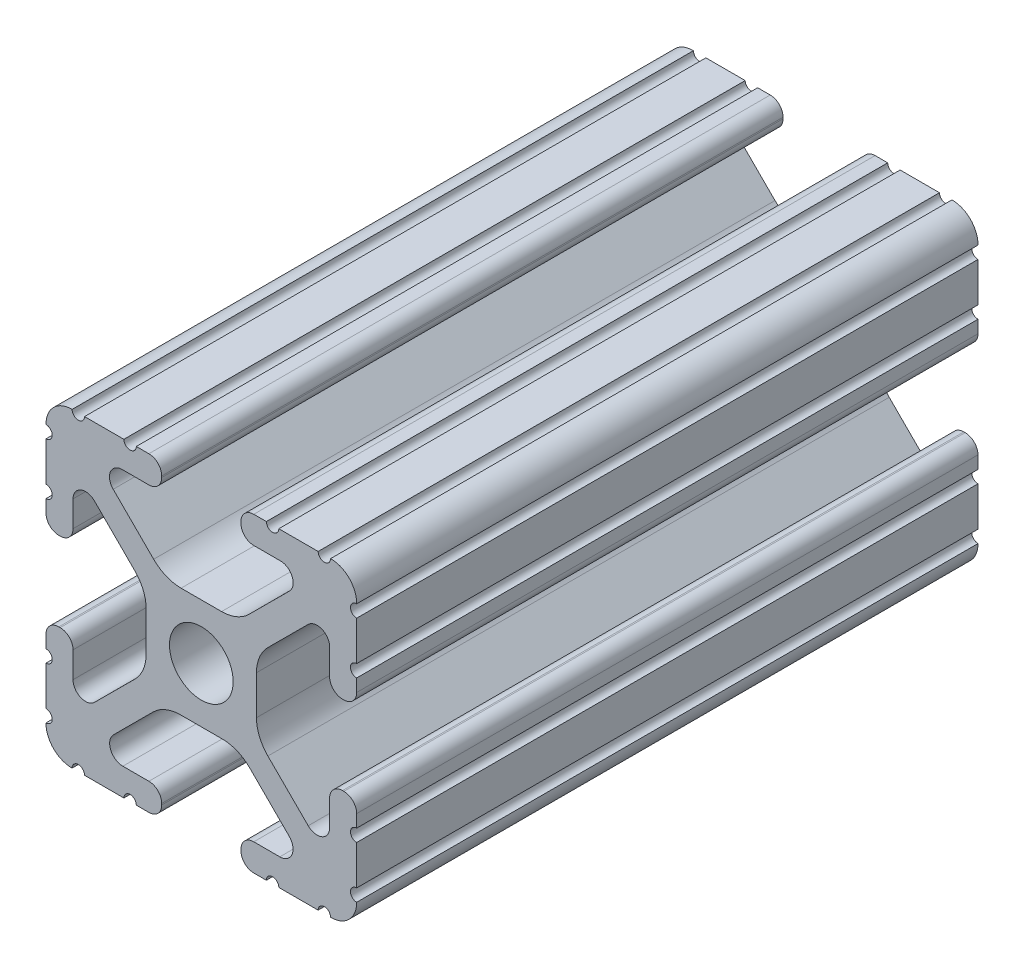
from build123d import *

# Parameters (mm, degrees)
SKETCH1_R               = 2.6035
BOSS_EXTRUDE1_DEPTH     = 25.4
SKETCH2_R               = 3.175
CUT_EXTRUDE1_DEPTH      = 13.7
CUT_EXTRUDE1_DEPTH_BACK = 13.7


with BuildPart() as part:
    # Sketch1 → Boss-Extrude1 (new body, symmetric)
    with BuildSketch(Plane.XY):
        with BuildLine():
            Line((-7.179650497, -8.645192506), (-3.952270251, -5.423690499))
            ThreePointArc((-3.952270251, -5.423690499), (-2.922936451, -4.736929036), (-1.709253557, -4.4958))
            Line((-1.709253557, -4.4958), (1.709253557, -4.4958))
            ThreePointArc((1.709253557, -4.4958), (2.922936451, -4.736929036), (3.952270251, -5.423690499))
            Line((3.952270251, -5.423690499), (7.179650497, -8.645192506))
            ThreePointArc((7.179650497, -8.645192506), (7.41473083, -9.822813117), (6.416408329, -10.4902))
            Line((6.416408329, -10.4902), (4.287512407, -10.4902))
            ThreePointArc((4.287512407, -10.4902), (3.54574862, -10.79744862), (3.2385, -11.539212407))
            Line((3.2385, -11.539212407), (3.2385, -11.650987593))
            ThreePointArc((3.2385, -11.650987593), (3.54574862, -12.39275138), (4.287512407, -12.7))
            Line((4.287512407, -12.7), (5.317126718, -12.7))
            ThreePointArc((5.317126718, -12.7), (5.825126718, -12.192), (6.333126718, -12.7))
            Line((6.333126718, -12.7), (9.550443118, -12.7))
            ThreePointArc((9.550443118, -12.7), (10.058366869, -12.192000006), (10.566443095, -12.699847501))
            ThreePointArc((10.566443095, -12.699847501), (12.082537762, -12.08250727), (12.699846982, -10.566399977))
            ThreePointArc((12.699846982, -10.566399977), (12.192000006, -10.058323491), (12.7, -9.5504))
            Line((12.7, -9.5504), (12.7, -6.3330836))
            ThreePointArc((12.7, -6.3330836), (12.192, -5.8250836), (12.7, -5.3170836))
            Line((12.7, -5.3170836), (12.7, -4.287469289))
            ThreePointArc((12.7, -4.287469289), (12.39275138, -3.545705502), (11.650987593, -3.238456882))
            Line((11.650987593, -3.238456882), (11.539212407, -3.238456882))
            ThreePointArc((11.539212407, -3.238456882), (10.79744862, -3.545705502), (10.4902, -4.287469289))
            Line((10.4902, -4.287469289), (10.4902, -6.402089023))
            ThreePointArc((10.4902, -6.402089023), (9.856505071, -7.351067942), (8.737131347, -7.129408934))
            Line((8.737131347, -7.129408934), (5.441005833, -3.840816462))
            ThreePointArc((5.441005833, -3.840816462), (4.750877967, -2.809883091), (4.5085, -1.593185507))
            Line((4.5085, -1.593185507), (4.5085, 1.593185507))
            ThreePointArc((4.5085, 1.593185507), (4.750877967, 2.809883091), (5.441005833, 3.840816462))
            Line((5.441005833, 3.840816462), (8.737131347, 7.129408934))
            ThreePointArc((8.737131347, 7.129408934), (9.856505071, 7.351067942), (10.4902, 6.402089023))
            Line((10.4902, 6.402089023), (10.4902, 4.287469289))
            ThreePointArc((10.4902, 4.287469289), (10.79744862, 3.545705502), (11.539212407, 3.238456882))
            Line((11.539212407, 3.238456882), (11.650987593, 3.238456882))
            ThreePointArc((11.650987593, 3.238456882), (12.39275138, 3.545705502), (12.7, 4.287469289))
            Line((12.7, 4.287469289), (12.7, 5.3170836))
            ThreePointArc((12.7, 5.3170836), (12.192, 5.8250836), (12.7, 6.3330836))
            Line((12.7, 6.3330836), (12.7, 9.5504))
            ThreePointArc((12.7, 9.5504), (12.192000006, 10.058323491), (12.699846982, 10.566399977))
            ThreePointArc((12.699846982, 10.566399977), (12.082537762, 12.08250727), (10.566443095, 12.699847501))
            ThreePointArc((10.566443095, 12.699847501), (10.058366869, 12.192000006), (9.550443118, 12.7))
            Line((9.550443118, 12.7), (6.333126718, 12.7))
            ThreePointArc((6.333126718, 12.7), (5.825126718, 12.192), (5.317126718, 12.7))
            Line((5.317126718, 12.7), (4.287512407, 12.7))
            ThreePointArc((4.287512407, 12.7), (3.54574862, 12.39275138), (3.2385, 11.650987593))
            Line((3.2385, 11.650987593), (3.2385, 11.539212407))
            ThreePointArc((3.2385, 11.539212407), (3.54574862, 10.79744862), (4.287512407, 10.4902))
            Line((4.287512407, 10.4902), (6.476788598, 10.4902))
            ThreePointArc((6.476788598, 10.4902), (7.432222385, 9.85140422), (7.207036008, 8.724370562))
            Line((7.207036008, 8.724370562), (3.898272566, 5.423169045))
            ThreePointArc((3.898272566, 5.423169045), (2.869120213, 4.736787962), (1.655778399, 4.4958))
            Line((1.655778399, 4.4958), (-1.655778399, 4.4958))
            ThreePointArc((-1.655778399, 4.4958), (-2.869120213, 4.736787962), (-3.898272566, 5.423169045))
            Line((-3.898272566, 5.423169045), (-7.207036008, 8.724370562))
            ThreePointArc((-7.207036008, 8.724370562), (-7.432222385, 9.85140422), (-6.476788598, 10.4902))
            Line((-6.476788598, 10.4902), (-4.287512407, 10.4902))
            ThreePointArc((-4.287512407, 10.4902), (-3.54574862, 10.79744862), (-3.2385, 11.539212407))
            Line((-3.2385, 11.539212407), (-3.2385, 11.650987593))
            ThreePointArc((-3.2385, 11.650987593), (-3.54574862, 12.39275138), (-4.287512407, 12.7))
            Line((-4.287512407, 12.7), (-5.317126718, 12.7))
            ThreePointArc((-5.317126718, 12.7), (-5.825126718, 12.192), (-6.333126718, 12.7))
            Line((-6.333126718, 12.7), (-9.550443118, 12.7))
            ThreePointArc((-9.550443118, 12.7), (-10.058366869, 12.192000006), (-10.566443095, 12.699847501))
            ThreePointArc((-10.566443095, 12.699847501), (-12.082537762, 12.08250727), (-12.699846982, 10.566399977))
            ThreePointArc((-12.699846982, 10.566399977), (-12.192000006, 10.058323491), (-12.7, 9.5504))
            Line((-12.7, 9.5504), (-12.7, 6.3330836))
            ThreePointArc((-12.7, 6.3330836), (-12.192, 5.8250836), (-12.7, 5.3170836))
            Line((-12.7, 5.3170836), (-12.7, 4.287469289))
            ThreePointArc((-12.7, 4.287469289), (-12.39275138, 3.545705502), (-11.650987593, 3.238456882))
            Line((-11.650987593, 3.238456882), (-11.539212407, 3.238456882))
            ThreePointArc((-11.539212407, 3.238456882), (-10.79744862, 3.545705502), (-10.4902, 4.287469289))
            Line((-10.4902, 4.287469289), (-10.4902, 6.402089023))
            ThreePointArc((-10.4902, 6.402089023), (-9.856505071, 7.351067942), (-8.737131347, 7.129408934))
            Line((-8.737131347, 7.129408934), (-5.441005833, 3.840816462))
            ThreePointArc((-5.441005833, 3.840816462), (-4.750877967, 2.809883091), (-4.5085, 1.593185507))
            Line((-4.5085, 1.593185507), (-4.5085, -1.593185507))
            ThreePointArc((-4.5085, -1.593185507), (-4.750877967, -2.809883091), (-5.441005833, -3.840816462))
            Line((-5.441005833, -3.840816462), (-8.737131347, -7.129408934))
            ThreePointArc((-8.737131347, -7.129408934), (-9.856505071, -7.351067942), (-10.4902, -6.402089023))
            Line((-10.4902, -6.402089023), (-10.4902, -4.287469289))
            ThreePointArc((-10.4902, -4.287469289), (-10.79744862, -3.545705502), (-11.539212407, -3.238456882))
            Line((-11.539212407, -3.238456882), (-11.650987593, -3.238456882))
            ThreePointArc((-11.650987593, -3.238456882), (-12.39275138, -3.545705502), (-12.7, -4.287469289))
            Line((-12.7, -4.287469289), (-12.7, -5.3170836))
            ThreePointArc((-12.7, -5.3170836), (-12.192, -5.8250836), (-12.7, -6.3330836))
            Line((-12.7, -6.3330836), (-12.7, -9.5504))
            ThreePointArc((-12.7, -9.5504), (-12.192000006, -10.058323491), (-12.699846982, -10.566399977))
            ThreePointArc((-12.699846982, -10.566399977), (-12.082537762, -12.08250727), (-10.566443095, -12.699847501))
            ThreePointArc((-10.566443095, -12.699847501), (-10.058366869, -12.192000006), (-9.550443118, -12.7))
            Line((-9.550443118, -12.7), (-6.333126718, -12.7))
            ThreePointArc((-6.333126718, -12.7), (-5.825126718, -12.192), (-5.317126718, -12.7))
            Line((-5.317126718, -12.7), (-4.287512407, -12.7))
            ThreePointArc((-4.287512407, -12.7), (-3.54574862, -12.39275138), (-3.2385, -11.650987593))
            Line((-3.2385, -11.650987593), (-3.2385, -11.539212407))
            ThreePointArc((-3.2385, -11.539212407), (-3.54574862, -10.79744862), (-4.287512407, -10.4902))
            Line((-4.287512407, -10.4902), (-6.416408329, -10.4902))
            ThreePointArc((-6.416408329, -10.4902), (-7.41473083, -9.822813117), (-7.179650497, -8.645192506))
        make_face()
        Circle(SKETCH1_R, mode=Mode.SUBTRACT)
    extrude(amount=BOSS_EXTRUDE1_DEPTH, both=True)

    # Sketch2 → Cut-Extrude1 (cut, two sides)
    with BuildSketch(Plane(origin=(0, 0, 0), x_dir=(1, 0, 0), z_dir=(0, 1, 0))) as cut_extrude1_sk:
        with Locations((0, 12.7)):
            Circle(SKETCH2_R)
        with Locations((0, -15.875)):
            Circle(SKETCH2_R)
    extrude(amount=CUT_EXTRUDE1_DEPTH, mode=Mode.SUBTRACT)
    extrude(cut_extrude1_sk.sketch, amount=-CUT_EXTRUDE1_DEPTH_BACK, mode=Mode.SUBTRACT)


solid = part.part
